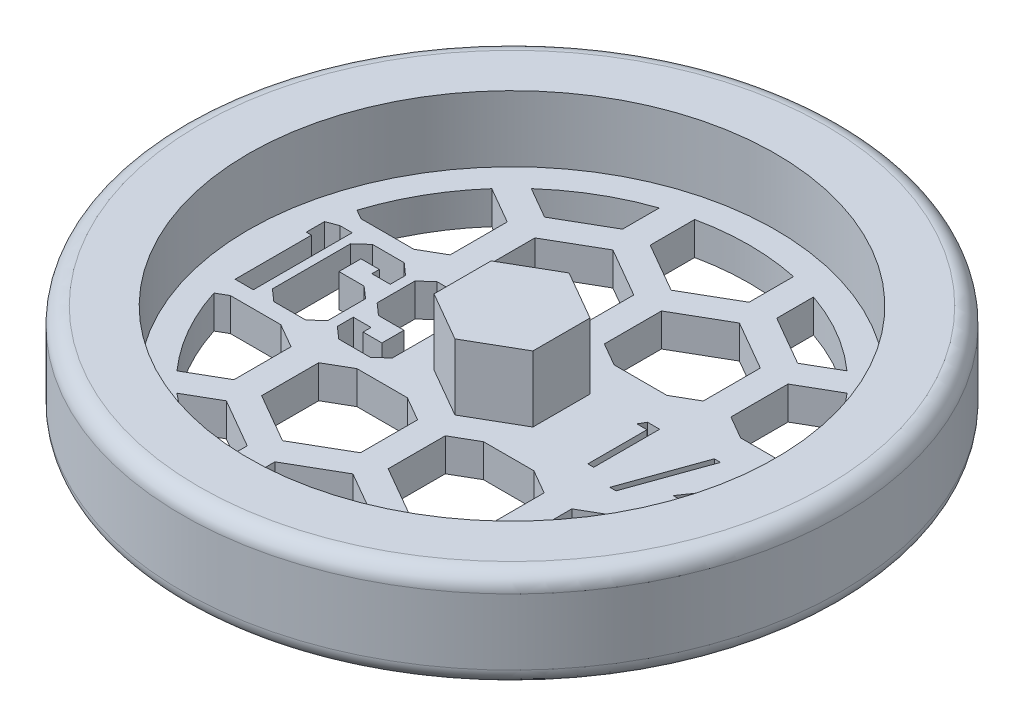
from build123d import *

# Parameters (mm, degrees)
BOSS_EXTRUDE1_DEPTH     = 6.35
CUT_EXTRUDE1_DEPTH      = 7.3500001
CUT_EXTRUDE1_DEPTH_BACK = 4.175
CUT_EXTRUDE3_DEPTH      = 7.3500001
CUT_EXTRUDE3_DEPTH_BACK = 4.175


with BuildPart() as part:
    # Sketch1 → Revolve1 (revolve)
    with BuildSketch(Plane.XY):
        with BuildLine():
            Line((0, 0), (30.1625, 0))
            ThreePointArc((30.1625, 0), (31.285032015, 0.464967985), (31.75, 1.5875))
            Line((31.75, 1.5875), (31.75, 7.9375))
            ThreePointArc((31.75, 7.9375), (31.285032015, 9.060032015), (30.1625, 9.525))
            Line((30.1625, 9.525), (25.4, 9.525))
            Line((25.4, 9.525), (25.4, 3.175))
            Line((25.4, 3.175), (0, 3.175))
            Line((0, 3.175), (0, 0))
        make_face()
    revolve(axis=Axis((0, 3.175, 0), (0, -1, 0)))

    # Sketch2 → Boss-Extrude1 (add)
    with BuildSketch(Plane(origin=(0, 3.175, 0), x_dir=(1, 0, 0), z_dir=(0, 1, 0))):
        Polygon((0, -5.499261314), (4.7625, -2.749630657), (4.7625, 2.749630657), (0, 5.499261314), (-4.7625, 2.749630657), (-4.7625, -2.749630657), align=None)
    extrude(amount=BOSS_EXTRUDE1_DEPTH)

    # Sketch3 → Cut-Extrude1 (cut, two sides)
    with BuildSketch(Plane(origin=(0, 3.175, 0), x_dir=(1, 0, 0), z_dir=(0, 1, 0))) as cut_extrude1_sk:
        Polygon((-20.156339589, -4.7625), (-21.915105149, -4.7625), (-21.915105149, 2.597727273), (-22.418122878, 2.597727273), (-22.418122878, 4.356492833), (-21.333041777, 4.7625), (-20.156339589, 4.7625), align=None)
        Polygon((-14.001558374, -3.767243493), (-15.129755281, -4.7625), (-18.185587986, -4.7625), (-19.313784892, -3.767243493), (-19.313784892, 3.761854017), (-18.198163429, 4.7625), (-15.1477202, 4.7625), (-14.019523293, 3.761854017), (-14.019523293, 2.288730668), (-15.783678329, 2.288730668), (-15.783678329, 3.00373444), (-17.555019332, 3.00373444), (-17.555019332, 0.882077518), (-15.129755281, 0.882077518), (-14.001558374, -0.105993022), align=None)
        Polygon((-7.769528008, -3.767243493), (-8.895928423, -4.7625), (-11.928406733, -4.7625), (-13.05660364, -3.767243493), (-13.05660364, -2.234835911), (-11.340953885, -2.234835911), (-11.340953885, -3.00373444), (-9.526497077, -3.00373444), (-9.526497077, -0.882077518), (-11.98230149, -0.882077518), (-13.105108921, 0.113178989), (-13.105108921, 3.761854017), (-11.98230149, 4.7625), (-8.908503866, 4.7625), (-7.769528008, 3.756464542), align=None)
        Polygon((9.877353766, 3.175), (11.051442308, 3.175), (11.051442308, -3.175), (10.481570513, -3.175), (10.481570513, 2.523717949), (9.504647436, 2.523717949), align=None)
        Polygon((16.750160256, 3.337820513), (14.094150641, -4.070512821), (13.49375, -4.070512821), (16.149759615, 3.337820513), align=None)
        Polygon((20.704917869, 3.337820513), (20.820673077, 3.337820513), (20.820673077, -1.058333333), (21.553365385, -1.058333333), (21.553365385, -1.709615385), (20.820673077, -1.709615385), (20.820673077, -3.175), (20.250801282, -3.175), (20.250801282, -1.709615385), (17.238621795, -1.709615385), align=None)
    extrude(amount=CUT_EXTRUDE1_DEPTH, mode=Mode.SUBTRACT)
    extrude(cut_extrude1_sk.sketch, amount=-CUT_EXTRUDE1_DEPTH_BACK, mode=Mode.SUBTRACT)

    # Sketch4 → Cut-Extrude3 (cut, two sides)
    with BuildSketch(Plane(origin=(0, 3.175, 0), x_dir=(1, 0, 0), z_dir=(0, 1, 0))) as cut_extrude3_sk:
        with BuildLine():
            Line((-20.897368408, 6.35), (-15.805631592, 6.35))
            Line((-15.805631592, 6.35), (-13.589, 7.629772846))
            Line((-13.589, 7.629772846), (-13.589, 13.12903416))
            Line((-13.589, 13.12903416), (-17.108932059, 15.161267882))
            ThreePointArc((-17.108932059, 15.161267882), (-19.892207199, 11.264088635), (-21.802466353, 6.872558542))
            Line((-21.802466353, 6.872558542), (-20.897368408, 6.35))
        make_face()
        with BuildLine():
            ThreePointArc((-7.4295, 21.619022405), (-11.544244404, 19.730940706), (-15.206214659, 17.068996331))
            Line((-15.206214659, 17.068996331), (-12.192, 15.328738686))
            Line((-12.192, 15.328738686), (-7.4295, 18.078369343))
            Line((-7.4295, 18.078369343), (-7.4295, 21.619022405))
        make_face()
        Polygon((-8.705368408, 6.35), (-3.613631592, 6.35), (-1.397, 7.629772846), (-1.397, 13.12903416), (-6.1595, 15.878664817), (-10.922, 13.12903416), (-10.922, 7.629772846), align=None)
        with BuildLine():
            ThreePointArc((4.7625, 22.358403202), (0, 22.86), (-4.7625, 22.358403202))
            Line((-4.7625, 22.358403202), (-4.7625, 18.078369343))
            Line((-4.7625, 18.078369343), (0, 15.328738686))
            Line((0, 15.328738686), (4.7625, 18.078369343))
            Line((4.7625, 18.078369343), (4.7625, 22.358403202))
        make_face()
        Polygon((1.27, 7.629772846), (3.486631592, 6.35), (8.578368408, 6.35), (10.795, 7.629772846), (10.795, 13.12903416), (6.0325, 15.878664817), (1.27, 13.12903416), align=None)
        with BuildLine():
            Line((12.192, 15.328738686), (15.206214659, 17.068996331))
            ThreePointArc((15.206214659, 17.068996331), (11.544244404, 19.730940706), (7.4295, 21.619022405))
            Line((7.4295, 21.619022405), (7.4295, 18.078369343))
            Line((7.4295, 18.078369343), (12.192, 15.328738686))
        make_face()
        with BuildLine():
            Line((13.462, 7.629772846), (15.678631592, 6.35))
            Line((15.678631592, 6.35), (20.770368408, 6.35))
            Line((20.770368408, 6.35), (21.782830062, 6.934545009))
            ThreePointArc((21.782830062, 6.934545009), (19.860135036, 11.320540463), (17.065866333, 15.209727358))
            Line((17.065866333, 15.209727358), (13.462, 13.12903416))
            Line((13.462, 13.12903416), (13.462, 7.629772846))
        make_face()
        with BuildLine():
            Line((20.650522628, -6.35), (15.798477372, -6.35))
            Line((15.798477372, -6.35), (13.462, -7.69896584))
            Line((13.462, -7.69896584), (13.462, -13.198227154))
            Line((13.462, -13.198227154), (17.025077395, -15.255370847))
            ThreePointArc((17.025077395, -15.255370847), (19.829723184, -11.373727554), (21.764149656, -6.992952864))
            Line((21.764149656, -6.992952864), (20.650522628, -6.35))
        make_face()
        with BuildLine():
            ThreePointArc((7.4295, -21.619022405), (11.544244404, -19.730940706), (15.206214659, -17.068996331))
            Line((15.206214659, -17.068996331), (12.192, -15.328738686))
            Line((12.192, -15.328738686), (7.4295, -18.078369343))
            Line((7.4295, -18.078369343), (7.4295, -21.619022405))
        make_face()
        Polygon((8.458522628, -6.35), (3.606477372, -6.35), (1.27, -7.69896584), (1.27, -13.198227154), (6.0325, -15.947857811), (10.795, -13.198227154), (10.795, -7.69896584), align=None)
        with BuildLine():
            Line((-4.7625, -18.078369343), (-4.7625, -22.358403202))
            ThreePointArc((-4.7625, -22.358403202), (0, -22.86), (4.7625, -22.358403202))
            Line((4.7625, -22.358403202), (4.7625, -18.078369343))
            Line((4.7625, -18.078369343), (0, -15.328738686))
            Line((0, -15.328738686), (-4.7625, -18.078369343))
        make_face()
        Polygon((-1.397, -7.69896584), (-3.733477372, -6.35), (-8.585522628, -6.35), (-10.922, -7.69896584), (-10.922, -13.198227154), (-6.1595, -15.947857811), (-1.397, -13.198227154), align=None)
        with BuildLine():
            Line((-12.192, -15.328738686), (-15.206214659, -17.068996331))
            ThreePointArc((-15.206214659, -17.068996331), (-11.544244404, -19.730940706), (-7.4295, -21.619022405))
            Line((-7.4295, -21.619022405), (-7.4295, -18.078369343))
            Line((-7.4295, -18.078369343), (-12.192, -15.328738686))
        make_face()
        with BuildLine():
            Line((-13.589, -7.69896584), (-15.925477372, -6.35))
            Line((-15.925477372, -6.35), (-20.777522628, -6.35))
            Line((-20.777522628, -6.35), (-21.783940581, -6.931055676))
            ThreePointArc((-21.783940581, -6.931055676), (-19.861945981, -11.317362848), (-17.068296652, -15.207000013))
            Line((-17.068296652, -15.207000013), (-13.589, -13.198227154))
            Line((-13.589, -13.198227154), (-13.589, -7.69896584))
        make_face()
    extrude(amount=CUT_EXTRUDE3_DEPTH, mode=Mode.SUBTRACT)
    extrude(cut_extrude3_sk.sketch, amount=-CUT_EXTRUDE3_DEPTH_BACK, mode=Mode.SUBTRACT)


solid = part.part
